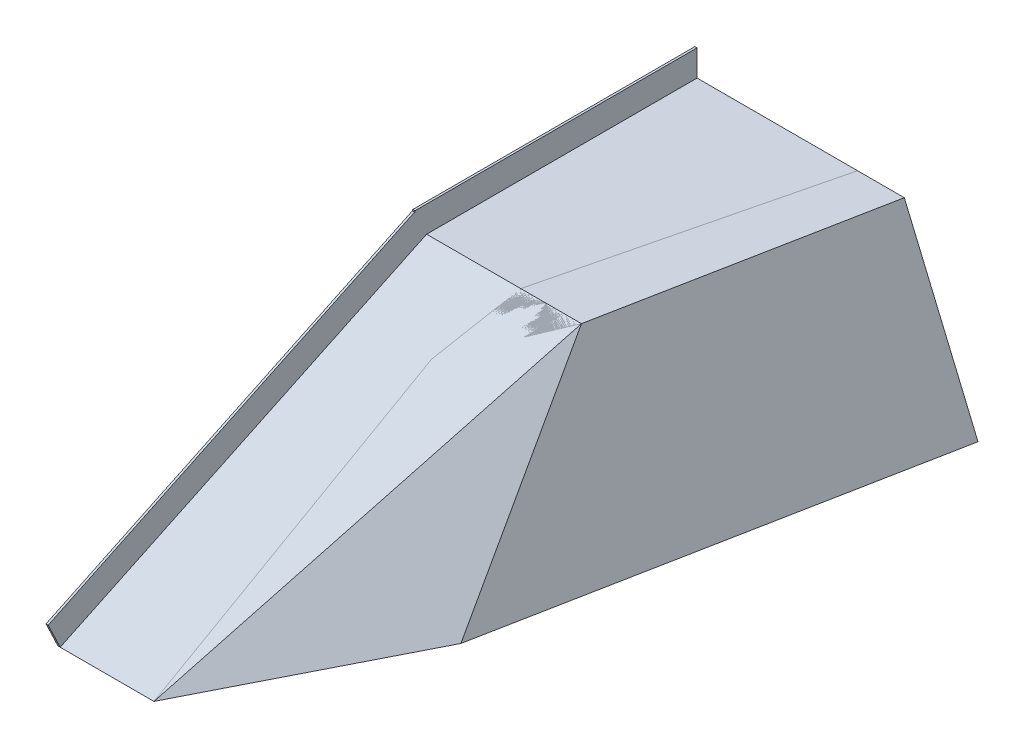
from build123d import *

# Parameters (mm, degrees)
BOSS_EXTRUDE1_DEPTH = 508
CUT_EXTRUDE1_DEPTH  = 508
BOSS_EXTRUDE2_DEPTH = 508
BOSS_EXTRUDE3_DEPTH = 635
CUT_EXTRUDE3_DEPTH  = 1016
CUT_EXTRUDE6_DEPTH  = 508
CUT_EXTRUDE7_DEPTH  = 1016
CUT_EXTRUDE8_DEPTH  = 1016
CUT_EXTRUDE9_DEPTH  = 1016
SKETCH10_W          = 6.35
SKETCH10_H          = 821.479258641
BOSS_EXTRUDE4_DEPTH = 76.2
SKETCH11_W          = 6.35
SKETCH11_H          = 1181.577860321
BOSS_EXTRUDE6_DEPTH = 81.28


with BuildPart() as part:
    # Sketch1 → Boss-Extrude1 (new body)
    with BuildSketch(Plane(origin=(0, 0, 0), x_dir=(1, 0, 0), z_dir=(0, 1, 0))):
        Polygon((0, 1066.8), (0, 0), (279.4, 0), (457.2, 1066.8), align=None)
    extrude(amount=BOSS_EXTRUDE1_DEPTH)

    # Sketch2 → Cut-Extrude1 (cut)
    with BuildSketch(Plane.ZY):
        Polygon((0, 0), (-1066.8, 508), (-1066.8, 732.672417782), (0, 732.672417782), align=None)
    extrude(amount=-CUT_EXTRUDE1_DEPTH, mode=Mode.SUBTRACT)

    # Sketch3 → Boss-Extrude2 (add)
    with BuildSketch(Plane.XZ):
        Polygon((0, -1066.8), (0, -1854.2), (609.6, -1854.2), (457.2, -1066.8), align=None)
    extrude(amount=-BOSS_EXTRUDE2_DEPTH)

    # Sketch10 → Boss-Extrude4 (add)
    with BuildSketch(Plane(origin=(0, 508, 0), x_dir=(1, 0, 0), z_dir=(0, 1, 0))):
        with Locations((3.175, 1443.46037068)):
            Rectangle(SKETCH10_W, SKETCH10_H)
    extrude(amount=BOSS_EXTRUDE4_DEPTH)

    # Sketch11 → Boss-Extrude6 (add)
    with BuildSketch(Plane(origin=(0, 0, 0), x_dir=(1, 0, 0), z_dir=(0, 0.902860519, 0.42993358))):
        with Locations((3.175, 590.788930161)):
            Rectangle(SKETCH11_W, SKETCH11_H)
    extrude(amount=BOSS_EXTRUDE6_DEPTH)


with BuildPart() as body_2:
    # Sketch4 → Boss-Extrude3 (new body)
    with BuildSketch(Plane.XZ):
        Polygon((279.4, 0), (758.024602406, -943.929756814), (824.163316724, -1854.2), (609.6, -1854.2), (473.605368522, -1854.2), (229.324151542, -858.00394067), align=None)
    extrude(amount=-BOSS_EXTRUDE3_DEPTH)

    # Sketch5 → Cut-Extrude3 (cut)
    with BuildSketch(Plane(origin=(158.02566363, 112.959299077, 80.127753023), x_dir=(-0.31022669, -0.221755053, 0.924437179), z_dir=(-0.752056745, -0.537582319, -0.381334371))):
        Polygon((-393.664649125, 703.625608499), (953.241894052, -176.928807588), (-1326.842790058, -923.556364957), (-2274.788319735, -628.326732027), (-2325.528348512, 172.375821483), align=None)
    extrude(amount=-CUT_EXTRUDE3_DEPTH, mode=Mode.SUBTRACT)

    # Sketch6 → Cut-Extrude6 (cut)
    with BuildSketch(Plane(origin=(397.94007399, 254.27896004, 77.020659482), x_dir=(0.135641307, 0.086673177, -0.986959572), z_dir=(0.831669714, 0.531427026, 0.160968332))):
        Polygon((1082.533011894, 1261.854611528), (2538.800510351, 767.688534421), (2437.604130324, -1113.046367909), (306.999460867, -1023.580096849), align=None)
    extrude(amount=CUT_EXTRUDE6_DEPTH, mode=Mode.SUBTRACT)

    # Sketch7 → Cut-Extrude7 (cut)
    with BuildSketch(Plane(origin=(0, 0, 0), x_dir=(1, 0, 0), z_dir=(0, 0.902860519, 0.42993358))):
        Polygon((0, 1181.577860321), (0, 0), (1197.045935399, 0), (1543.879463505, 955.927792479), (976.352766556, 2301.292030359), align=None)
    extrude(amount=CUT_EXTRUDE7_DEPTH, mode=Mode.SUBTRACT)

    # Sketch8 → Cut-Extrude8 (cut)
    with BuildSketch(Plane(origin=(382.681643927, 161.632761359, 74.067414954), x_dir=(0.161697356, 0.068295907, -0.984474293), z_dir=(0.906898891, 0.383045736, 0.175528818))):
        Polygon((1197.556798458, 999.143883777), (2455.295967915, 323.49765858), (2410.705423203, -956.043074474), (776.288597468, -956.043074474), (430.351182168, -503.275200855), align=None)
    extrude(amount=CUT_EXTRUDE8_DEPTH, mode=Mode.SUBTRACT)

    # Sketch9 → Cut-Extrude9 (cut)
    with BuildSketch(Plane(origin=(0, 508, 0), x_dir=(1, 0, 0), z_dir=(0, 1, 0))):
        Polygon((351.522364305, 2301.225932819), (1863.401978722, 1800.09916747), (1313.944223798, 629.194662402), (-286.938271333, 375.015467974), (-444.004316346, 1364.25568729), align=None)
    extrude(amount=CUT_EXTRUDE9_DEPTH, mode=Mode.SUBTRACT)


solid = Compound([part.part, body_2.part])
